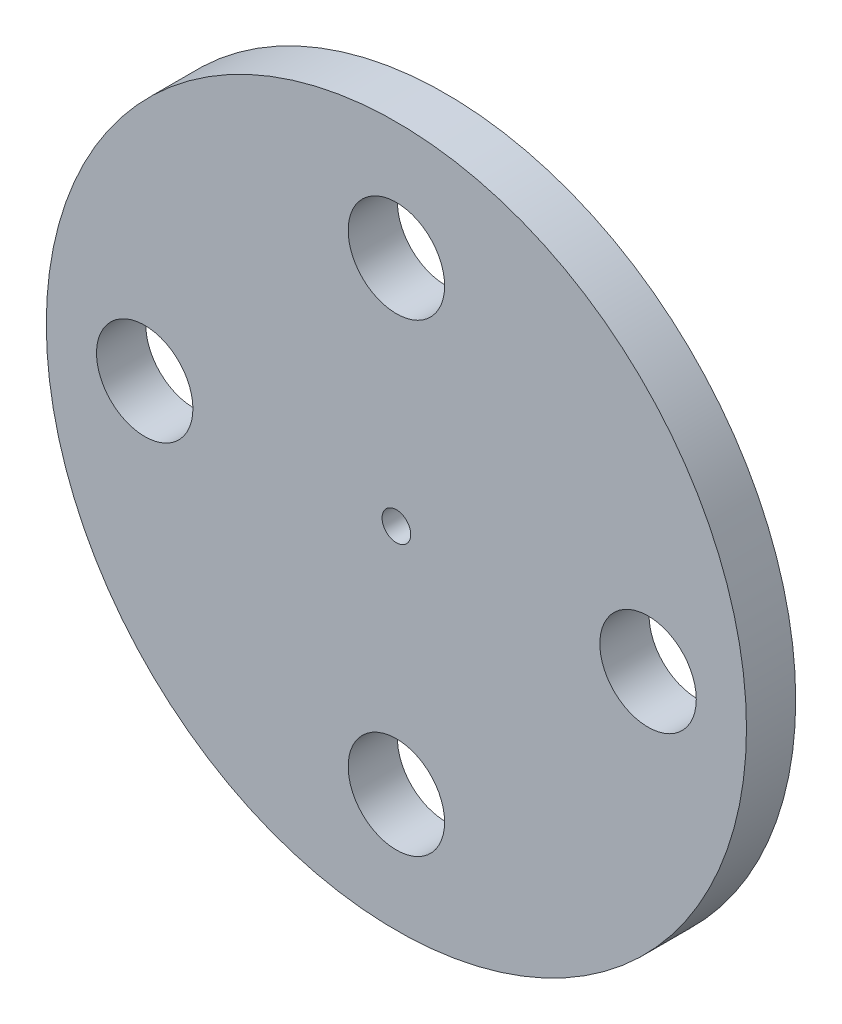
from build123d import *

# Parameters (mm, degrees)
SKETCH1_R           = 22.614280448
SKETCH1_R_2         = 0.925
SKETCH1_R_3         = 3.112808362
SKETCH1_R_4         = 3.115
BOSS_EXTRUDE5_DEPTH = 3.18


with BuildPart() as part:
    # Sketch1 → Boss-Extrude5 (new body)
    with BuildSketch(Plane.XY):
        Circle(SKETCH1_R)
        Circle(SKETCH1_R_2, mode=Mode.SUBTRACT)
        with Locations((-16.255928567, 0)):
            Circle(SKETCH1_R_3, mode=Mode.SUBTRACT)
        with Locations((0, -15)):
            Circle(SKETCH1_R_4, mode=Mode.SUBTRACT)
        with Locations((16.255928567, 0)):
            Circle(SKETCH1_R_4, mode=Mode.SUBTRACT)
        with Locations((0, 15)):
            Circle(SKETCH1_R_4, mode=Mode.SUBTRACT)
    extrude(amount=BOSS_EXTRUDE5_DEPTH)


solid = part.part
